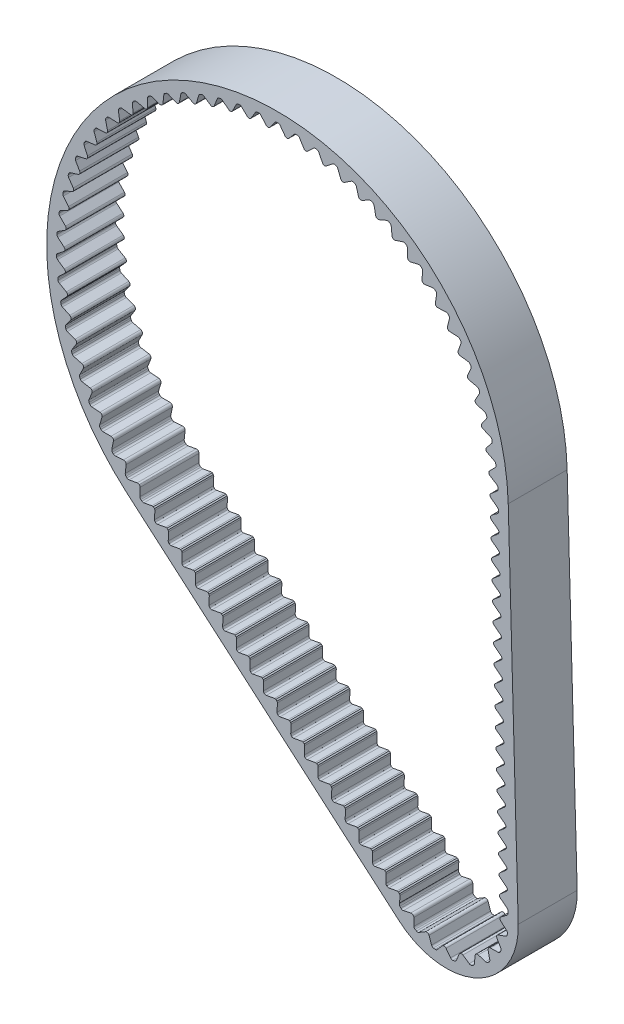
from build123d import *

# Parameters (mm, degrees)
EXTRUSION1_DEPTH = 6


with BuildPart() as part:
    # Esquisse1 → Extrusion1 (new body)
    with BuildSketch(Plane.XY.offset(6)):
        with BuildLine():
            Line((-15.334373102, -17.807498465), (12.39087959, -41.68223696))
            ThreePointArc((12.39087959, -41.68223696), (20.327023581, -42.748267068), (24.509319529, -35.919855668))
            Line((24.509319529, -35.919855668), (23.490894598, 0.654118489))
            ThreePointArc((23.490894598, 0.654118489), (-10.091582426, 21.222864183), (-15.334373102, -17.807498465))
        make_face()
        with BuildLine():
            Line((22.696897189, -34.530290534), (23.358806003, -35.04004493))
            ThreePointArc((23.358806003, -35.04004493), (23.431470071, -35.129563447), (23.45623381, -35.242170679))
            Line((23.45623381, -35.242170679), (23.444067585, -35.24187801))
            ThreePointArc((23.444067585, -35.24187801), (23.452635322, -35.269269708), (23.458007178, -35.29746287))
            ThreePointArc((23.458007178, -35.29746287), (23.467697998, -35.374773495), (23.476437242, -35.452197459))
            ThreePointArc((23.476437242, -35.452197459), (23.45702328, -35.578601158), (23.377639226, -35.678865651))
            Line((23.377639226, -35.678865651), (22.755214675, -36.144674693))
            ThreePointArc((22.755214675, -36.144674693), (22.65519241, -36.335200136), (22.740250266, -36.532860347))
            Line((22.740250266, -36.532860347), (23.324967395, -37.045204239))
            ThreePointArc((23.324967395, -37.045204239), (23.396397014, -37.151282542), (23.406022193, -37.278805688))
            ThreePointArc((23.406022193, -37.278805688), (23.391348414, -37.35532709), (23.375734608, -37.431662231))
            ThreePointArc((23.375734608, -37.431662231), (23.318209943, -37.545880047), (23.211727788, -37.616706225))
            Line((23.211727788, -37.616706225), (22.475823953, -37.867377186))
            ThreePointArc((22.475823953, -37.867377186), (22.321821526, -38.01766907), (22.34163599, -38.231939425))
            Line((22.34163599, -38.231939425), (22.739412056, -38.899894952))
            ThreePointArc((22.739412056, -38.899894952), (22.774565662, -39.02285438), (22.744312933, -39.147110442))
            ThreePointArc((22.744312933, -39.147110442), (22.706710926, -39.215352173), (22.668272458, -39.283126275))
            ThreePointArc((22.668272458, -39.283126275), (22.578268003, -39.373977774), (22.455110964, -39.408432676))
            Line((22.455110964, -39.408432676), (21.677763239, -39.419428136))
            ThreePointArc((21.677763239, -39.419428136), (21.484855482, -39.514774845), (21.437486976, -39.724681068))
            Line((21.437486976, -39.724681068), (21.609384886, -40.482864089))
            ThreePointArc((21.609384886, -40.482864089), (21.604821399, -40.610668516), (21.537652108, -40.719494446))
            ThreePointArc((21.537652108, -40.719494446), (21.48080262, -40.77277653), (21.423302116, -40.825355391))
            ThreePointArc((21.423302116, -40.825355391), (21.309628136, -40.883947396), (21.18185168, -40.878658337))
            Line((21.18185168, -40.878658337), (20.439152277, -40.648901983))
            ThreePointArc((20.439152277, -40.648901983), (20.226222344, -40.679970317), (20.116307628, -40.864965324))
            Line((20.116307628, -40.864965324), (20.045500817, -41.639159603))
            ThreePointArc((20.045500817, -41.639159603), (20.001666943, -41.75929864), (19.90415609, -41.842041798))
            ThreePointArc((19.90415609, -41.842041798), (19.833623944, -41.875148613), (19.762689953, -41.907385449))
            ThreePointArc((19.762689953, -41.907385449), (19.636473648, -41.927982565), (19.516585427, -41.883467274))
            Line((19.516585427, -41.883467274), (18.881234938, -41.43544926))
            ThreePointArc((18.881234938, -41.43544926), (18.669125894, -41.399198033), (18.507424186, -41.541173225))
            Line((18.507424186, -41.541173225), (18.200843718, -42.255595231))
            ThreePointArc((18.200843718, -42.255595231), (18.122030223, -42.356308834), (18.003722848, -42.404869742))
            ThreePointArc((18.003722848, -42.404869742), (17.926412223, -42.414560563), (17.848988259, -42.423299807))
            ThreePointArc((17.848988259, -42.423299807), (17.722584561, -42.403885845), (17.622320067, -42.32450179))
            Line((17.622320067, -42.32450179), (17.156511025, -41.702077239))
            ThreePointArc((17.156511025, -41.702077239), (16.965985582, -41.602054975), (16.768325372, -41.687112831))
            Line((16.768325372, -41.687112831), (16.255981479, -42.27182996))
            ThreePointArc((16.255981479, -42.27182996), (16.149903176, -42.343259578), (16.02238003, -42.352884758))
            ThreePointArc((16.02238003, -42.352884758), (15.945858629, -42.338210979), (15.869523488, -42.322597173))
            ThreePointArc((15.869523488, -42.322597173), (15.755305671, -42.265072507), (15.684479493, -42.158590352))
            Line((15.684479493, -42.158590352), (15.433808532, -41.422686517))
            ThreePointArc((15.433808532, -41.422686517), (15.283516648, -41.268684091), (15.069246294, -41.288498555))
            Line((15.069246294, -41.288498555), (14.401290766, -41.68627462))
            ThreePointArc((14.401290766, -41.68627462), (14.278331339, -41.721428227), (14.154075276, -41.691175497))
            ThreePointArc((14.154075276, -41.691175497), (14.085833545, -41.65357349), (14.018059444, -41.615135023))
            ThreePointArc((14.018059444, -41.615135023), (13.927207944, -41.525130568), (13.892753042, -41.401973528))
            Line((13.892753042, -41.401973528), (13.881757582, -40.624625803))
            ThreePointArc((13.881757582, -40.624625803), (13.786410873, -40.431718046), (13.57650465, -40.38434954))
            Line((13.57650465, -40.38434954), (12.818321629, -40.55624745))
            ThreePointArc((12.818321629, -40.55624745), (12.690517202, -40.551683964), (12.581691272, -40.484514673))
            ThreePointArc((12.581691272, -40.484514673), (12.557507119, -40.458884888), (12.533465906, -40.433120975))
            Line((12.533465906, -40.433120975), (12.529931343, -40.437684395))
            ThreePointArc((12.529931343, -40.437684395), (12.489724532, -40.397890711), (12.459493698, -40.350076261))
            ThreePointArc((12.459493698, -40.350076261), (12.414775023, -40.243776449), (12.422527382, -40.128714244))
            Line((12.422527382, -40.128714244), (12.438908993, -40.075759831))
            Line((12.438908993, -40.075759831), (12.457051161, -39.399390639))
            ThreePointArc((12.457051161, -39.399390639), (12.448764535, -39.32837889), (12.420717879, -39.262616273))
            Line((12.420717879, -39.262616273), (12.304238174, -39.162313401))
            ThreePointArc((12.304238174, -39.162313401), (12.234237521, -39.144160107), (12.161969594, -39.146802114))
            Line((12.161969594, -39.146802114), (11.340272659, -39.297755652))
            ThreePointArc((11.340272659, -39.297755652), (11.225124598, -39.291877256), (11.124860429, -39.234949864))
            Line((11.124860429, -39.234949864), (11.128174206, -39.230671498))
            ThreePointArc((11.128174206, -39.230671498), (11.06804321, -39.1444171), (11.04869629, -39.041066945))
            Line((11.04869629, -39.041066945), (11.071097344, -38.205919643))
            ThreePointArc((11.071097344, -38.205919643), (11.062810718, -38.134907894), (11.034764062, -38.069145277))
            Line((11.034764062, -38.069145277), (10.918284358, -37.968842405))
            ThreePointArc((10.918284358, -37.968842405), (10.848283704, -37.950689111), (10.776015777, -37.953331118))
            Line((10.776015777, -37.953331118), (9.954318843, -38.104284656))
            ThreePointArc((9.954318843, -38.104284656), (9.839170781, -38.09840626), (9.738906612, -38.041478869))
            Line((9.738906612, -38.041478869), (9.742220389, -38.037200502))
            ThreePointArc((9.742220389, -38.037200502), (9.682089393, -37.950946104), (9.662742474, -37.847595949))
            Line((9.662742474, -37.847595949), (9.685143527, -37.012448647))
            ThreePointArc((9.685143527, -37.012448647), (9.676856902, -36.941436898), (9.648810245, -36.875674281))
            Line((9.648810245, -36.875674281), (9.532330541, -36.775371409))
            ThreePointArc((9.532330541, -36.775371409), (9.462329888, -36.757218115), (9.39006196, -36.759860122))
            Line((9.39006196, -36.759860122), (8.568365026, -36.91081366))
            ThreePointArc((8.568365026, -36.91081366), (8.453216965, -36.904935265), (8.352952796, -36.848007873))
            Line((8.352952796, -36.848007873), (8.356266572, -36.843729506))
            ThreePointArc((8.356266572, -36.843729506), (8.296135577, -36.757475108), (8.276788657, -36.654124953))
            Line((8.276788657, -36.654124953), (8.299189711, -35.818977652))
            ThreePointArc((8.299189711, -35.818977652), (8.290903085, -35.747965902), (8.262856429, -35.682203286))
            Line((8.262856429, -35.682203286), (8.146376724, -35.581900413))
            ThreePointArc((8.146376724, -35.581900413), (8.076376071, -35.563747119), (8.004108144, -35.566389126))
            Line((8.004108144, -35.566389126), (7.182411209, -35.717342665))
            ThreePointArc((7.182411209, -35.717342665), (7.067263148, -35.711464269), (6.966998979, -35.654536877))
            Line((6.966998979, -35.654536877), (6.970312756, -35.65025851))
            ThreePointArc((6.970312756, -35.65025851), (6.91018176, -35.564004112), (6.89083484, -35.460653957))
            Line((6.89083484, -35.460653957), (6.913235894, -34.625506656))
            ThreePointArc((6.913235894, -34.625506656), (6.904949268, -34.554494907), (6.876902612, -34.48873229))
            Line((6.876902612, -34.48873229), (6.760422908, -34.388429417))
            ThreePointArc((6.760422908, -34.388429417), (6.690422254, -34.370276123), (6.618154327, -34.37291813))
            Line((6.618154327, -34.37291813), (5.796457393, -34.523871669))
            ThreePointArc((5.796457393, -34.523871669), (5.681309331, -34.517993273), (5.581045162, -34.461065881))
            Line((5.581045162, -34.461065881), (5.584358939, -34.456787515))
            ThreePointArc((5.584358939, -34.456787515), (5.524227943, -34.370533116), (5.504881024, -34.267182961))
            Line((5.504881024, -34.267182961), (5.527282077, -33.43203566))
            ThreePointArc((5.527282077, -33.43203566), (5.518995452, -33.361023911), (5.490948795, -33.295261294))
            Line((5.490948795, -33.295261294), (5.374469091, -33.194958422))
            ThreePointArc((5.374469091, -33.194958422), (5.304468438, -33.176805128), (5.23220051, -33.179447134))
            Line((5.23220051, -33.179447134), (4.410503576, -33.330400673))
            ThreePointArc((4.410503576, -33.330400673), (4.295355515, -33.324522277), (4.195091346, -33.267594885))
            Line((4.195091346, -33.267594885), (4.198405122, -33.263316519))
            ThreePointArc((4.198405122, -33.263316519), (4.138274127, -33.177062121), (4.118927207, -33.073711966))
            Line((4.118927207, -33.073711966), (4.141328261, -32.238564664))
            ThreePointArc((4.141328261, -32.238564664), (4.133041635, -32.167552915), (4.104994979, -32.101790298))
            Line((4.104994979, -32.101790298), (3.988515274, -32.001487426))
            ThreePointArc((3.988515274, -32.001487426), (3.918514621, -31.983334132), (3.846246693, -31.985976139))
            Line((3.846246693, -31.985976139), (3.024549759, -32.136929677))
            ThreePointArc((3.024549759, -32.136929677), (2.909401698, -32.131051281), (2.809137529, -32.074123889))
            Line((2.809137529, -32.074123889), (2.812451306, -32.069845523))
            ThreePointArc((2.812451306, -32.069845523), (2.75232031, -31.983591125), (2.73297339, -31.88024097))
            Line((2.73297339, -31.88024097), (2.755374444, -31.045093668))
            ThreePointArc((2.755374444, -31.045093668), (2.747087818, -30.974081919), (2.719041162, -30.908319302))
            Line((2.719041162, -30.908319302), (2.602561458, -30.80801643))
            ThreePointArc((2.602561458, -30.80801643), (2.532560804, -30.789863136), (2.460292877, -30.792505143))
            Line((2.460292877, -30.792505143), (1.638595942, -30.943458681))
            ThreePointArc((1.638595942, -30.943458681), (1.523447881, -30.937580285), (1.423183712, -30.880652893))
            Line((1.423183712, -30.880652893), (1.426497489, -30.876374527))
            ThreePointArc((1.426497489, -30.876374527), (1.366366493, -30.790120129), (1.347019573, -30.686769974))
            Line((1.347019573, -30.686769974), (1.369420627, -29.851622672))
            ThreePointArc((1.369420627, -29.851622672), (1.361134001, -29.780610923), (1.333087345, -29.714848306))
            Line((1.333087345, -29.714848306), (1.216607641, -29.614545434))
            ThreePointArc((1.216607641, -29.614545434), (1.146606988, -29.59639214), (1.07433906, -29.599034147))
            Line((1.07433906, -29.599034147), (0.252642126, -29.749987685))
            ThreePointArc((0.252642126, -29.749987685), (0.137494065, -29.744109289), (0.037229896, -29.687181898))
            Line((0.037229896, -29.687181898), (0.040543672, -29.682903531))
            ThreePointArc((0.040543672, -29.682903531), (-0.019587323, -29.596649133), (-0.038934243, -29.493298978))
            Line((-0.038934243, -29.493298978), (-0.01653319, -28.658151676))
            ThreePointArc((-0.01653319, -28.658151676), (-0.024819815, -28.587139927), (-0.052866472, -28.52137731))
            Line((-0.052866472, -28.52137731), (-0.169346176, -28.421074438))
            ThreePointArc((-0.169346176, -28.421074438), (-0.239346829, -28.402921144), (-0.311614757, -28.405563151))
            Line((-0.311614757, -28.405563151), (-1.133311691, -28.556516689))
            ThreePointArc((-1.133311691, -28.556516689), (-1.248459752, -28.550638294), (-1.348723921, -28.493710902))
            Line((-1.348723921, -28.493710902), (-1.345410144, -28.489432535))
            ThreePointArc((-1.345410144, -28.489432535), (-1.40554114, -28.403178137), (-1.42488806, -28.299827982))
            Line((-1.42488806, -28.299827982), (-1.402487006, -27.464680681))
            ThreePointArc((-1.402487006, -27.464680681), (-1.410773632, -27.393668931), (-1.438820288, -27.327906315))
            Line((-1.438820288, -27.327906315), (-1.555299993, -27.227603442))
            ThreePointArc((-1.555299993, -27.227603442), (-1.625300646, -27.209450148), (-1.697568573, -27.212092155))
            Line((-1.697568573, -27.212092155), (-2.519265508, -27.363045694))
            ThreePointArc((-2.519265508, -27.363045694), (-2.634413569, -27.357167298), (-2.734677738, -27.300239906))
            Line((-2.734677738, -27.300239906), (-2.731363961, -27.295961539))
            ThreePointArc((-2.731363961, -27.295961539), (-2.791494957, -27.209707141), (-2.810841877, -27.106356986))
            Line((-2.810841877, -27.106356986), (-2.788440823, -26.271209685))
            ThreePointArc((-2.788440823, -26.271209685), (-2.796727449, -26.200197935), (-2.824774105, -26.134435319))
            Line((-2.824774105, -26.134435319), (-2.941253809, -26.034132446))
            ThreePointArc((-2.941253809, -26.034132446), (-3.011254463, -26.015979152), (-3.08352239, -26.018621159))
            Line((-3.08352239, -26.018621159), (-3.905219324, -26.169574698))
            ThreePointArc((-3.905219324, -26.169574698), (-4.020367386, -26.163696302), (-4.120631555, -26.10676891))
            Line((-4.120631555, -26.10676891), (-4.117317778, -26.102490544))
            ThreePointArc((-4.117317778, -26.102490544), (-4.177448774, -26.016236145), (-4.196795693, -25.91288599))
            Line((-4.196795693, -25.91288599), (-4.17439464, -25.077738689))
            ThreePointArc((-4.17439464, -25.077738689), (-4.182681265, -25.00672694), (-4.210727922, -24.940964323))
            Line((-4.210727922, -24.940964323), (-4.327207626, -24.840661451))
            ThreePointArc((-4.327207626, -24.840661451), (-4.397208279, -24.822508157), (-4.469476207, -24.825150163))
            Line((-4.469476207, -24.825150163), (-5.291173141, -24.976103702))
            ThreePointArc((-5.291173141, -24.976103702), (-5.406321202, -24.970225306), (-5.506585371, -24.913297914))
            Line((-5.506585371, -24.913297914), (-5.503271595, -24.909019548))
            ThreePointArc((-5.503271595, -24.909019548), (-5.56340259, -24.82276515), (-5.58274951, -24.719414995))
            Line((-5.58274951, -24.719414995), (-5.560348456, -23.884267693))
            ThreePointArc((-5.560348456, -23.884267693), (-5.568635082, -23.813255944), (-5.596681738, -23.747493327))
            Line((-5.596681738, -23.747493327), (-5.713161443, -23.647190455))
            ThreePointArc((-5.713161443, -23.647190455), (-5.783162096, -23.629037161), (-5.855430023, -23.631679168))
            Line((-5.855430023, -23.631679168), (-6.677126958, -23.782632706))
            ThreePointArc((-6.677126958, -23.782632706), (-6.792275019, -23.77675431), (-6.892539188, -23.719826918))
            Line((-6.892539188, -23.719826918), (-6.889225411, -23.715548552))
            ThreePointArc((-6.889225411, -23.715548552), (-6.949356407, -23.629294154), (-6.968703327, -23.525943999))
            Line((-6.968703327, -23.525943999), (-6.946302273, -22.690796697))
            ThreePointArc((-6.946302273, -22.690796697), (-6.954588899, -22.619784948), (-6.982635555, -22.554022331))
            Line((-6.982635555, -22.554022331), (-7.099115259, -22.453719459))
            ThreePointArc((-7.099115259, -22.453719459), (-7.169115913, -22.435566165), (-7.24138384, -22.438208172))
            Line((-7.24138384, -22.438208172), (-8.063080774, -22.58916171))
            ThreePointArc((-8.063080774, -22.58916171), (-8.178228836, -22.583283314), (-8.278493005, -22.526355922))
            Line((-8.278493005, -22.526355922), (-8.275179228, -22.522077556))
            ThreePointArc((-8.275179228, -22.522077556), (-8.335310224, -22.435823158), (-8.354657144, -22.332473003))
            Line((-8.354657144, -22.332473003), (-8.33225609, -21.497325701))
            ThreePointArc((-8.33225609, -21.497325701), (-8.340542715, -21.426313952), (-8.368589372, -21.360551335))
            Line((-8.368589372, -21.360551335), (-8.485069076, -21.260248463))
            ThreePointArc((-8.485069076, -21.260248463), (-8.555069729, -21.242095169), (-8.627337657, -21.244737176))
            Line((-8.627337657, -21.244737176), (-9.449034591, -21.395690714))
            ThreePointArc((-9.449034591, -21.395690714), (-9.564182652, -21.389812318), (-9.664446821, -21.332884926))
            Line((-9.664446821, -21.332884926), (-9.661133045, -21.32860656))
            ThreePointArc((-9.661133045, -21.32860656), (-9.72126404, -21.242352162), (-9.74061096, -21.139002007))
            Line((-9.74061096, -21.139002007), (-9.718209907, -20.303854705))
            ThreePointArc((-9.718209907, -20.303854705), (-9.726496532, -20.232842956), (-9.754543188, -20.167080339))
            Line((-9.754543188, -20.167080339), (-9.871022893, -20.066777467))
            ThreePointArc((-9.871022893, -20.066777467), (-9.941023546, -20.048624173), (-10.013291474, -20.05126618))
            Line((-10.013291474, -20.05126618), (-10.834988408, -20.202219718))
            ThreePointArc((-10.834988408, -20.202219718), (-10.950136469, -20.196341323), (-11.050400638, -20.139413931))
            Line((-11.050400638, -20.139413931), (-11.047086861, -20.135135564))
            ThreePointArc((-11.047086861, -20.135135564), (-11.107217857, -20.048881166), (-11.126564777, -19.945531011))
            Line((-11.126564777, -19.945531011), (-11.104163723, -19.11038371))
            ThreePointArc((-11.104163723, -19.11038371), (-11.112450349, -19.03937196), (-11.140497005, -18.973609344))
            Line((-11.140497005, -18.973609344), (-11.25697671, -18.873306471))
            ThreePointArc((-11.25697671, -18.873306471), (-11.326977363, -18.855153177), (-11.39924529, -18.857795184))
            Line((-11.39924529, -18.857795184), (-12.220942225, -19.008748723))
            ThreePointArc((-12.220942225, -19.008748723), (-12.336090286, -19.002870327), (-12.436354455, -18.945942935))
            Line((-12.436354455, -18.945942935), (-12.433040678, -18.941664568))
            ThreePointArc((-12.433040678, -18.941664568), (-12.493171674, -18.85541017), (-12.512518594, -18.752060015))
            Line((-12.512518594, -18.752060015), (-12.49011754, -17.916912714))
            ThreePointArc((-12.49011754, -17.916912714), (-12.498404166, -17.845900964), (-12.526450822, -17.780138348))
            Line((-12.526450822, -17.780138348), (-12.642930526, -17.679835475))
            ThreePointArc((-12.642930526, -17.679835475), (-12.71293118, -17.661682181), (-12.785199107, -17.664324188))
            Line((-12.785199107, -17.664324188), (-13.606896041, -17.815277727))
            ThreePointArc((-13.606896041, -17.815277727), (-13.711359306, -17.812259718), (-13.80546151, -17.766801414))
            ThreePointArc((-13.80546151, -17.766801414), (-13.861098453, -17.7234294), (-13.916599136, -17.679883158))
            ThreePointArc((-13.916599136, -17.679883158), (-13.988310863, -17.589599938), (-14.011880372, -17.476736703))
            Line((-14.011880372, -17.476736703), (-13.989479318, -16.641589402))
            ThreePointArc((-13.989479318, -16.641589402), (-14.009390978, -16.536902879), (-14.071091487, -16.450019111))
            Line((-14.071091487, -16.450019111), (-14.081548407, -16.44101446))
            ThreePointArc((-14.081548407, -16.44101446), (-14.177341376, -16.392708393), (-14.284560886, -16.389000876))
            Line((-14.284560886, -16.389000876), (-15.10625782, -16.539954415))
            ThreePointArc((-15.10625782, -16.539954415), (-15.221405881, -16.534076019), (-15.32167005, -16.477148627))
            ThreePointArc((-15.32167005, -16.477148627), (-15.373256052, -16.429029136), (-15.424690931, -16.380748142))
            ThreePointArc((-15.424690931, -16.380748142), (-15.488142796, -16.284480327), (-15.501645209, -16.16997567))
            Line((-15.501645209, -16.16997567), (-15.405521409, -15.340076256))
            ThreePointArc((-15.405521409, -15.340076256), (-15.475139808, -15.136501671), (-15.677124469, -15.062396815))
            Line((-15.677124469, -15.062396815), (-16.508947246, -15.140137984))
            ThreePointArc((-16.508947246, -15.140137984), (-16.62312518, -15.124105794), (-16.717965748, -15.058539811))
            ThreePointArc((-16.717965748, -15.058539811), (-16.76509708, -15.006049444), (-16.812063605, -14.953411562))
            ThreePointArc((-16.812063605, -14.953411562), (-16.866759012, -14.851912577), (-16.870088654, -14.736662653))
            Line((-16.870088654, -14.736662653), (-16.700994407, -13.918506215))
            ThreePointArc((-16.700994407, -13.918506215), (-16.752348434, -13.709575372), (-16.946993298, -13.617909076))
            Line((-16.946993298, -13.617909076), (-17.782431777, -13.621829446))
            ThreePointArc((-17.782431777, -13.621829446), (-17.894745985, -13.595768935), (-17.983420697, -13.522077504))
            ThreePointArc((-17.983420697, -13.522077504), (-18.025728491, -13.465627069), (-18.067859087, -13.409044262))
            ThreePointArc((-18.067859087, -13.409044262), (-18.11336997, -13.303108475), (-18.106500783, -13.18801527))
            Line((-18.106500783, -13.18801527), (-17.865759479, -12.388004991))
            ThreePointArc((-17.865759479, -12.388004991), (-17.898447219, -12.175353058), (-18.084228926, -12.066842734))
            Line((-18.084228926, -12.066842734), (-18.916744669, -11.996911623))
            ThreePointArc((-18.916744669, -11.996911623), (-19.026316141, -11.96102675), (-19.108130997, -11.879786607))
            ThreePointArc((-19.108130997, -11.879786607), (-19.145284137, -11.819817905), (-19.182249074, -11.75973301))
            ThreePointArc((-19.182249074, -11.75973301), (-19.218219249, -11.650189512), (-19.201204992, -11.536153787))
            Line((-19.201204992, -11.536153787), (-18.89070076, -10.760550832))
            ThreePointArc((-18.89070076, -10.760550832), (-18.904466387, -10.545842098), (-19.079930944, -10.421336988))
            Line((-19.079930944, -10.421336988), (-19.903008385, -10.278101701))
            ThreePointArc((-19.903008385, -10.278101701), (-20.008979576, -10.232673313), (-20.083294263, -10.144520272))
            ThreePointArc((-20.083294263, -10.144520272), (-20.115001977, -10.08150264), (-20.146511954, -10.018385903))
            ThreePointArc((-20.146511954, -10.018385903), (-20.172659906, -9.90609202), (-20.145633739, -9.794006259))
            Line((-20.145633739, -9.794006259), (-19.767796695, -9.048880773))
            ThreePointArc((-19.767796695, -9.048880773), (-19.762532474, -8.833795625), (-19.926306632, -8.694270149))
            Line((-19.926306632, -8.694270149), (-20.733504076, -8.478851697))
            ThreePointArc((-20.733504076, -8.478851697), (-20.835045616, -8.424235334), (-20.901278522, -8.329859311))
            ThreePointArc((-20.901278522, -8.329859311), (-20.927292653, -8.264285947), (-20.953101062, -8.198631343))
            ThreePointArc((-20.953101062, -8.198631343), (-20.969222147, -8.084465927), (-20.932395588, -7.975207353))
            Line((-20.932395588, -7.975207353), (-20.490182819, -7.266390953))
            ThreePointArc((-20.490182819, -7.266390953), (-20.46592995, -7.052612723), (-20.616731954, -6.899158859))
            Line((-20.616731954, -6.899158859), (-21.401731985, -6.613243183))
            ThreePointArc((-21.401731985, -6.613243183), (-21.498049176, -6.549866292), (-21.555681937, -6.450005908))
            ThreePointArc((-21.555681937, -6.450005908), (-21.57579889, -6.382390013), (-21.595703745, -6.314711376))
            ThreePointArc((-21.595703745, -6.314711376), (-21.601671794, -6.199567927), (-21.555333059, -6.093991636))
            Line((-21.555333059, -6.093991636), (-21.05220548, -5.427031771))
            ThreePointArc((-21.05220548, -5.427031771), (-21.009153775, -5.216233565), (-21.145803395, -5.050052296))
            Line((-21.145803395, -5.050052296), (-21.902462324, -4.695877075))
            ThreePointArc((-21.902462324, -4.695877075), (-21.992801352, -4.624235665), (-22.041382916, -4.519672463))
            ThreePointArc((-22.041382916, -4.519672463), (-22.055445247, -4.450543222), (-22.069290766, -4.381370231))
            ThreePointArc((-22.069290766, -4.381370231), (-22.065059071, -4.266149902), (-22.009570824, -4.165082172))
            Line((-22.009570824, -4.165082172), (-21.44946609, -3.545198708))
            ThreePointArc((-21.44946609, -3.545198708), (-21.387952486, -3.339030307), (-21.509380254, -3.161422227))
            Line((-21.509380254, -3.161422227), (-22.231776199, -2.741759361))
            ThreePointArc((-22.231776199, -2.741759361), (-22.315430039, -2.662414124), (-22.354580187, -2.553966453))
            ThreePointArc((-22.354580187, -2.553966453), (-22.362477841, -2.483864897), (-22.370155663, -2.413738924))
            ThreePointArc((-22.370155663, -2.413738924), (-22.355757343, -2.29934347), (-22.291553855, -2.203575293))
            Line((-22.291553855, -2.203575293), (-21.678855545, -1.635619658))
            ThreePointArc((-21.678855545, -1.635619658), (-21.59936147, -1.43569461), (-21.704617049, -1.248049743))
            Line((-21.704617049, -1.248049743), (-22.387096282, -0.766183663))
            ThreePointArc((-22.387096282, -0.766183663), (-22.46341023, -0.679755583), (-22.49282256, -0.568272192))
            ThreePointArc((-22.49282256, -0.568272192), (-22.494493725, -0.497746961), (-22.495943763, -0.427216837))
            ThreePointArc((-22.495943763, -0.427216837), (-22.471491504, -0.314541557), (-22.399075254, -0.224822449))
            Line((-22.399075254, -0.224822449), (-21.738578563, 0.286760333))
            ThreePointArc((-21.738578563, 0.286760333), (-21.641726165, 0.478877345), (-21.729985788, 0.675090423))
            Line((-21.729985788, 0.675090423), (-22.367206984, 1.215388461))
            ThreePointArc((-22.367206984, 1.215388461), (-22.435583778, 1.308222967), (-22.455028099, 1.421869568))
            ThreePointArc((-22.455028099, 1.421869568), (-22.450459698, 1.49226652), (-22.445670601, 1.562648802))
            ThreePointArc((-22.445670601, 1.562648802), (-22.411355775, 1.672722069), (-22.331293519, 1.755689935))
            Line((-22.331293519, 1.755689935), (-21.628167729, 2.206896036))
            ThreePointArc((-21.628167729, 2.206896036), (-21.514715011, 2.389701435), (-21.585287925, 2.592947091))
            Line((-21.585287925, 2.592947091), (-22.172263964, 3.187448523))
            ThreePointArc((-22.172263964, 3.187448523), (-22.232168464, 3.285962899), (-22.241492598, 3.400883272))
            ThreePointArc((-22.241492598, 3.400883272), (-22.230720383, 3.470600992), (-22.219729634, 3.540284594))
            ThreePointArc((-22.219729634, 3.540284594), (-22.175820801, 3.646894378), (-22.088739134, 3.722461664))
            Line((-22.088739134, 3.722461664), (-21.348487158, 4.109759786))
            ThreePointArc((-21.348487158, 4.109759786), (-21.21932204, 4.281822871), (-21.271655918, 4.490510432))
            Line((-21.271655918, 4.490510432), (-21.803792916, 5.134562478))
            ThreePointArc((-21.803792916, 5.134562478), (-21.854756289, 5.237985716), (-21.85388726, 5.353280453))
            ThreePointArc((-21.85388726, 5.353280453), (-21.83699554, 5.421773305), (-21.819889155, 5.49021286))
            ThreePointArc((-21.819889155, 5.49021286), (-21.766729962, 5.592524793), (-21.673310416, 5.660100085))
            Line((-21.673310416, 5.660100085), (-20.901725729, 5.980459092))
            ThreePointArc((-20.901725729, 5.980459092), (-20.757859104, 6.140433237), (-20.791544362, 6.352929441))
            Line((-20.791544362, 6.352929441), (-21.264677626, 7.04149152))
            ThreePointArc((-21.264677626, 7.04149152), (-21.306301013, 7.149014193), (-21.295245625, 7.263780956))
            ThreePointArc((-21.295245625, 7.263780956), (-21.2723666, 7.330512892), (-21.24927846, 7.397172766))
            ThreePointArc((-21.24927846, 7.397172766), (-21.187284948, 7.494386119), (-21.088258659, 7.553440548))
            Line((-21.088258659, 7.553440548), (-20.291379957, 7.804353198))
            ThreePointArc((-20.291379957, 7.804353198), (-20.133937776, 7.950986389), (-20.148710781, 8.165628163))
            Line((-20.148710781, 8.165628163), (-20.559137402, 8.893311343))
            ThreePointArc((-20.559137402, 8.893311343), (-20.591095044, 9.00409194), (-20.569939819, 9.117432524))
            ThreePointArc((-20.569939819, 9.117432524), (-20.541252548, 9.181881275), (-20.51236335, 9.246239766))
            ThreePointArc((-20.51236335, 9.246239766), (-20.442020704, 9.337593713), (-20.338162685, 9.387665097))
            Line((-20.338162685, 9.387665097), (-19.522226625, 9.567167658))
            ThreePointArc((-19.522226625, 9.567167658), (-19.352441087, 9.699312291), (-19.348186219, 9.914419773))
            Line((-19.348186219, 9.914419773), (-19.692694053, 10.675528948))
            ThreePointArc((-19.692694053, 10.675528948), (-19.714735838, 10.78870046), (-19.683646345, 10.899727821))
            ThreePointArc((-19.683646345, 10.899727821), (-19.649375345, 10.961388989), (-19.614911185, 11.022942403))
            ThreePointArc((-19.614911185, 11.022942403), (-19.53676993, 11.107721975), (-19.428893012, 11.148418438))
            Line((-19.428893012, 11.148418438), (-18.600285401, 11.25510606))
            ThreePointArc((-18.600285401, 11.25510606), (-18.419485307, 11.371727923), (-18.396235867, 11.585617607))
            Line((-18.396235867, 11.585617607), (-18.672128672, 12.374196064))
            ThreePointArc((-18.672128672, 12.374196064), (-18.684082094, 12.488872771), (-18.643301649, 12.59671797))
            ThreePointArc((-18.643301649, 12.59671797), (-18.603715137, 12.655108972), (-18.563945745, 12.71337557))
            ThreePointArc((-18.563945745, 12.71337557), (-18.478617444, 12.790917253), (-18.367565909, 12.82192029))
            Line((-18.367565909, 12.82192029), (-17.532771724, 12.854957997))
            ThreePointArc((-17.532771724, 12.854957997), (-17.34237208, 12.955144367), (-17.300310027, 13.166142274))
            Line((-17.300310027, 13.166142274), (-17.505428568, 13.976018318))
            ThreePointArc((-17.505428568, 13.976018318), (-17.507200075, 14.09130272), (-17.457047841, 14.195121721))
            ThreePointArc((-17.457047841, 14.195121721), (-17.412455635, 14.249785569), (-17.367692259, 14.304309336))
            ThreePointArc((-17.367692259, 14.304309336), (-17.275844721, 14.37400626), (-17.1624877, 14.395073231))
            Line((-17.1624877, 14.395073231), (-16.328040336, 14.354202458))
            ThreePointArc((-16.328040336, 14.354202458), (-16.129531278, 14.43716924), (-16.068985805, 14.643624026))
            Line((-16.068985805, 14.643624026), (-16.20172475, 15.468459279))
            ThreePointArc((-16.20172475, 15.468459279), (-16.193300477, 15.583449119), (-16.134168964, 15.682429398))
            ThreePointArc((-16.134168964, 15.682429398), (-16.084920059, 15.732938273), (-16.035513034, 15.783292487))
            ThreePointArc((-16.035513034, 15.783292487), (-15.93786509, 15.84459918), (-15.823089754, 15.855565206))
            Line((-15.823089754, 15.855565206), (-14.995519894, 15.741105822))
            ThreePointArc((-14.995519894, 15.741105822), (-14.790455025, 15.80620369), (-14.711899981, 16.006499566))
            Line((-14.711899981, 16.006499566), (-14.77122047, 16.839838574))
            ThreePointArc((-14.77122047, 16.839838574), (-14.752666348, 16.9536339), (-14.68501834, 17.047000802))
            ThreePointArc((-14.68501834, 17.047000802), (-14.631498175, 17.092959403), (-14.577834178, 17.138749975))
            ThreePointArc((-14.577834178, 17.138749975), (-14.475150055, 17.191186628), (-14.359854677, 17.191965886))
            Line((-14.359854677, 17.191965886), (-13.545639178, 17.004813691))
            ThreePointArc((-13.545639178, 17.004813691), (-13.335623408, 17.051533165), (-13.239673593, 17.244102545))
            Line((-13.239673593, 17.244102545), (-13.225111361, 18.0794233))
            ThreePointArc((-13.225111361, 18.0794233), (-13.196572603, 18.191133509), (-13.120937536, 18.278156312))
            ThreePointArc((-13.120937536, 18.278156312), (-13.063564979, 18.319204951), (-13.006064003, 18.360073506))
            ThreePointArc((-13.006064003, 18.360073506), (-12.899147345, 18.403229732), (-12.784234267, 18.393816123))
            Line((-12.784234267, 18.393816123), (-11.989745469, 18.135435837))
            ThreePointArc((-11.989745469, 18.135435837), (-11.776422456, 18.163411273), (-11.663828808, 18.34674704))
            Line((-11.663828808, 18.34674704), (-11.575497825, 19.177512025))
            ThreePointArc((-11.575497825, 19.177512025), (-11.537197784, 19.286262834), (-11.454167607, 19.366260466))
            ThreePointArc((-11.454167607, 19.366260466), (-11.393391676, 19.402077882), (-11.332503744, 19.437704569))
            ThreePointArc((-11.332503744, 19.437704569), (-11.222191318, 19.471242611), (-11.108559891, 19.451709809))
            Line((-11.108559891, 19.451709809), (-10.340015746, 19.124123609))
            ThreePointArc((-10.340015746, 19.124123609), (-10.125055031, 19.133136061), (-9.996698748, 19.305803365))
            Line((-9.996698748, 19.305803365), (-9.835290324, 20.125510717))
            ThreePointArc((-9.835290324, 20.125510717), (-9.78752875, 20.230451003), (-9.697753285, 20.302797374))
            ThreePointArc((-9.697753285, 20.302797374), (-9.634049634, 20.333103247), (-9.570251277, 20.363209238))
            ThreePointArc((-9.570251277, 20.363209238), (-9.457406428, 20.386866617), (-9.345945972, 20.357367493))
            Line((-9.345945972, 20.357367493), (-8.609361379, 19.963139183))
            ThreePointArc((-8.609361379, 19.963139183), (-8.394445323, 19.953118119), (-8.251330967, 20.113765602))
            Line((-8.251330967, 20.113765602), (-8.018108341, 20.916))
            ThreePointArc((-8.018108341, 20.916), (-7.961259033, 21.016308463), (-7.865440895, 21.080437365))
            ThreePointArc((-7.865440895, 21.080437365), (-7.799308092, 21.10499451), (-7.733098619, 21.129344186))
            ThreePointArc((-7.733098619, 21.129344186), (-7.61860451, 21.14293575), (-7.510187354, 21.103701175))
            Line((-7.510187354, 21.103701175), (-6.811327087, 20.645916127))
            ThreePointArc((-6.811327087, 20.645916127), (-6.598137699, 20.616939973), (-6.441385333, 20.764310352))
            Line((-6.441385333, 20.764310352), (-6.138173788, 21.542793224))
            ThreePointArc((-6.138173788, 21.542793224), (-6.072681669, 21.637684815), (-5.971570766, 21.693094352))
            ThreePointArc((-5.971570766, 21.693094352), (-5.903526389, 21.711710577), (-5.835423979, 21.730113368))
            ThreePointArc((-5.835423979, 21.730113368), (-5.720176682, 21.733532744), (-5.615651338, 21.684869781))
            Line((-5.615651338, 21.684869781), (-4.959984926, 21.167110784))
            ThreePointArc((-4.959984926, 21.167110784), (-4.7501907, 21.119406318), (-4.581027125, 21.252346221))
            Line((-4.581027125, 21.252346221), (-4.210199704, 22.000984883))
            ThreePointArc((-4.210199704, 22.000984883), (-4.136577338, 22.089716945), (-4.030965, 22.135973463))
            ThreePointArc((-4.030965, 22.135973463), (-3.961541589, 22.14850307), (-3.892079234, 22.16081495))
            ThreePointArc((-3.892079234, 22.16081495), (-3.776980716, 22.154035377), (-3.677165236, 22.09632488))
            Line((-3.677165236, 22.09632488), (-3.069824157, 21.5226441))
            ThreePointArc((-3.069824157, 21.5226441), (-2.86506702, 21.456584675), (-2.684816169, 21.574053665))
            Line((-2.684816169, 21.574053665), (-2.249275098, 22.286989005))
            ThreePointArc((-2.249275098, 22.286989005), (-2.168098681, 22.36886709), (-2.058811466, 22.405608569))
            ThreePointArc((-2.058811466, 22.405608569), (-1.988552353, 22.411953497), (-1.918273692, 22.418078108))
            ThreePointArc((-1.918273692, 22.418078108), (-1.804224754, 22.401152645), (-1.70990033, 22.334846277))
            Line((-1.70990033, 22.334846277), (-1.155637852, 21.709733544))
            ThreePointArc((-1.155637852, 21.709733544), (-0.957520305, 21.625836164), (-0.767592886, 21.726914889))
            Line((-0.767592886, 21.726914889), (-0.270746865, 22.39856722))
            ThreePointArc((-0.270746865, 22.39856722), (-0.182651712, 22.472950522), (-0.070544942, 22.499889409))
            ThreePointArc((-0.070544942, 22.499889409), (0, 22.5), (0.070544942, 22.499889409))
            ThreePointArc((0.070544942, 22.499889409), (0.182651712, 22.472950522), (0.270746865, 22.39856722))
            Line((0.270746865, 22.39856722), (0.767592886, 21.726914889))
            ThreePointArc((0.767592886, 21.726914889), (0.957520305, 21.625836164), (1.155637852, 21.709733544))
            Line((1.155637852, 21.709733544), (1.70990033, 22.334846277))
            ThreePointArc((1.70990033, 22.334846277), (1.804224754, 22.401152645), (1.918273692, 22.418078108))
            ThreePointArc((1.918273692, 22.418078108), (1.988552353, 22.411953497), (2.058811466, 22.405608569))
            ThreePointArc((2.058811466, 22.405608569), (2.168098681, 22.36886709), (2.249275098, 22.286989005))
            Line((2.249275098, 22.286989005), (2.684816169, 21.574053665))
            ThreePointArc((2.684816169, 21.574053665), (2.86506702, 21.456584675), (3.069824157, 21.5226441))
            Line((3.069824157, 21.5226441), (3.677165236, 22.09632488))
            ThreePointArc((3.677165236, 22.09632488), (3.776980716, 22.154035377), (3.892079234, 22.16081495))
            ThreePointArc((3.892079234, 22.16081495), (3.961541589, 22.14850307), (4.030965, 22.135973463))
            ThreePointArc((4.030965, 22.135973463), (4.136577338, 22.089716945), (4.210199704, 22.000984883))
            Line((4.210199704, 22.000984883), (4.581027125, 21.252346221))
            ThreePointArc((4.581027125, 21.252346221), (4.7501907, 21.119406318), (4.959984926, 21.167110784))
            Line((4.959984926, 21.167110784), (5.615651338, 21.684869781))
            ThreePointArc((5.615651338, 21.684869781), (5.720176682, 21.733532744), (5.835423979, 21.730113368))
            ThreePointArc((5.835423979, 21.730113368), (5.903526389, 21.711710577), (5.971570766, 21.693094352))
            ThreePointArc((5.971570766, 21.693094352), (6.072681669, 21.637684815), (6.138173788, 21.542793224))
            Line((6.138173788, 21.542793224), (6.441385333, 20.764310352))
            ThreePointArc((6.441385333, 20.764310352), (6.598137699, 20.616939973), (6.811327087, 20.645916127))
            Line((6.811327087, 20.645916127), (7.510187354, 21.103701175))
            ThreePointArc((7.510187354, 21.103701175), (7.61860451, 21.14293575), (7.733098619, 21.129344186))
            ThreePointArc((7.733098619, 21.129344186), (7.799308092, 21.10499451), (7.865440895, 21.080437365))
            ThreePointArc((7.865440895, 21.080437365), (7.961259033, 21.016308463), (8.018108341, 20.916))
            Line((8.018108341, 20.916), (8.251330967, 20.113765602))
            ThreePointArc((8.251330967, 20.113765602), (8.394445323, 19.953118119), (8.609361379, 19.963139183))
            Line((8.609361379, 19.963139183), (9.345945972, 20.357367493))
            ThreePointArc((9.345945972, 20.357367493), (9.457406428, 20.386866617), (9.570251277, 20.363209238))
            ThreePointArc((9.570251277, 20.363209238), (9.634049634, 20.333103247), (9.697753285, 20.302797374))
            ThreePointArc((9.697753285, 20.302797374), (9.78752875, 20.230451003), (9.835290324, 20.125510717))
            Line((9.835290324, 20.125510717), (9.996698748, 19.305803365))
            ThreePointArc((9.996698748, 19.305803365), (10.125055031, 19.133136061), (10.340015746, 19.124123609))
            Line((10.340015746, 19.124123609), (11.108559891, 19.451709809))
            ThreePointArc((11.108559891, 19.451709809), (11.222191318, 19.471242611), (11.332503744, 19.437704569))
            ThreePointArc((11.332503744, 19.437704569), (11.393391676, 19.402077882), (11.454167607, 19.366260466))
            ThreePointArc((11.454167607, 19.366260466), (11.537197784, 19.286262834), (11.575497825, 19.177512025))
            Line((11.575497825, 19.177512025), (11.663828808, 18.34674704))
            ThreePointArc((11.663828808, 18.34674704), (11.776422456, 18.163411273), (11.989745469, 18.135435837))
            Line((11.989745469, 18.135435837), (12.784234267, 18.393816123))
            ThreePointArc((12.784234267, 18.393816123), (12.899147345, 18.403229732), (13.006064003, 18.360073506))
            ThreePointArc((13.006064003, 18.360073506), (13.063564979, 18.319204951), (13.120937536, 18.278156312))
            ThreePointArc((13.120937536, 18.278156312), (13.196572603, 18.191133509), (13.225111361, 18.0794233))
            Line((13.225111361, 18.0794233), (13.239673593, 17.244102545))
            ThreePointArc((13.239673593, 17.244102545), (13.335623408, 17.051533165), (13.545639178, 17.004813691))
            Line((13.545639178, 17.004813691), (14.359854677, 17.191965886))
            ThreePointArc((14.359854677, 17.191965886), (14.475150055, 17.191186628), (14.577834178, 17.138749975))
            ThreePointArc((14.577834178, 17.138749975), (14.631498175, 17.092959403), (14.68501834, 17.047000802))
            ThreePointArc((14.68501834, 17.047000802), (14.752666348, 16.9536339), (14.77122047, 16.839838574))
            Line((14.77122047, 16.839838574), (14.711899981, 16.006499566))
            ThreePointArc((14.711899981, 16.006499566), (14.790455025, 15.80620369), (14.995519894, 15.741105822))
            Line((14.995519894, 15.741105822), (15.823089754, 15.855565206))
            ThreePointArc((15.823089754, 15.855565206), (15.93786509, 15.84459918), (16.035513034, 15.783292487))
            ThreePointArc((16.035513034, 15.783292487), (16.084920059, 15.732938273), (16.134168964, 15.682429398))
            ThreePointArc((16.134168964, 15.682429398), (16.193300477, 15.583449119), (16.20172475, 15.468459279))
            Line((16.20172475, 15.468459279), (16.068985805, 14.643624026))
            ThreePointArc((16.068985805, 14.643624026), (16.129531278, 14.43716924), (16.328040336, 14.354202458))
            Line((16.328040336, 14.354202458), (17.1624877, 14.395073231))
            ThreePointArc((17.1624877, 14.395073231), (17.275844721, 14.37400626), (17.367692259, 14.304309336))
            ThreePointArc((17.367692259, 14.304309336), (17.412455635, 14.249785569), (17.457047841, 14.195121721))
            ThreePointArc((17.457047841, 14.195121721), (17.507200075, 14.09130272), (17.505428568, 13.976018318))
            Line((17.505428568, 13.976018318), (17.300310027, 13.166142274))
            ThreePointArc((17.300310027, 13.166142274), (17.34237208, 12.955144367), (17.532771724, 12.854957997))
            Line((17.532771724, 12.854957997), (18.367565909, 12.82192029))
            ThreePointArc((18.367565909, 12.82192029), (18.478617444, 12.790917253), (18.563945745, 12.71337557))
            ThreePointArc((18.563945745, 12.71337557), (18.603715137, 12.655108972), (18.643301649, 12.59671797))
            ThreePointArc((18.643301649, 12.59671797), (18.684082094, 12.488872771), (18.672128672, 12.374196064))
            Line((18.672128672, 12.374196064), (18.396235867, 11.585617607))
            ThreePointArc((18.396235867, 11.585617607), (18.419485307, 11.371727923), (18.600285401, 11.25510606))
            Line((18.600285401, 11.25510606), (19.428893012, 11.148418438))
            ThreePointArc((19.428893012, 11.148418438), (19.53676993, 11.107721975), (19.614911185, 11.022942403))
            ThreePointArc((19.614911185, 11.022942403), (19.649375345, 10.961388989), (19.683646345, 10.899727821))
            ThreePointArc((19.683646345, 10.899727821), (19.714735838, 10.78870046), (19.692694053, 10.675528948))
            Line((19.692694053, 10.675528948), (19.348186219, 9.914419773))
            ThreePointArc((19.348186219, 9.914419773), (19.352441087, 9.699312291), (19.522226625, 9.567167658))
            Line((19.522226625, 9.567167658), (20.338162685, 9.387665097))
            ThreePointArc((20.338162685, 9.387665097), (20.442020704, 9.337593713), (20.51236335, 9.246239766))
            ThreePointArc((20.51236335, 9.246239766), (20.541252548, 9.181881275), (20.569939819, 9.117432524))
            ThreePointArc((20.569939819, 9.117432524), (20.591095044, 9.00409194), (20.559137402, 8.893311343))
            Line((20.559137402, 8.893311343), (20.148710781, 8.165628163))
            ThreePointArc((20.148710781, 8.165628163), (20.133937776, 7.950986389), (20.291379957, 7.804353198))
            Line((20.291379957, 7.804353198), (21.088258659, 7.553440548))
            ThreePointArc((21.088258659, 7.553440548), (21.187284948, 7.494386119), (21.24927846, 7.397172766))
            ThreePointArc((21.24927846, 7.397172766), (21.2723666, 7.330512892), (21.295245625, 7.263780956))
            ThreePointArc((21.295245625, 7.263780956), (21.306301013, 7.149014193), (21.264677626, 7.04149152))
            Line((21.264677626, 7.04149152), (20.791544362, 6.352929441))
            ThreePointArc((20.791544362, 6.352929441), (20.757859104, 6.140433237), (20.901725729, 5.980459092))
            Line((20.901725729, 5.980459092), (21.673310416, 5.660100085))
            ThreePointArc((21.673310416, 5.660100085), (21.766729962, 5.592524793), (21.819889155, 5.49021286))
            ThreePointArc((21.819889155, 5.49021286), (21.83699554, 5.421773305), (21.85388726, 5.353280453))
            ThreePointArc((21.85388726, 5.353280453), (21.854756289, 5.237985716), (21.803792916, 5.134562478))
            Line((21.803792916, 5.134562478), (21.271655918, 4.490510432))
            ThreePointArc((21.271655918, 4.490510432), (21.21932204, 4.281822871), (21.348487158, 4.109759786))
            Line((21.348487158, 4.109759786), (22.088739134, 3.722461664))
            ThreePointArc((22.088739134, 3.722461664), (22.175820801, 3.646894378), (22.219729634, 3.540284594))
            ThreePointArc((22.219729634, 3.540284594), (22.230720383, 3.470600992), (22.241492598, 3.400883272))
            ThreePointArc((22.241492598, 3.400883272), (22.232168464, 3.285962899), (22.172263964, 3.187448523))
            Line((22.172263964, 3.187448523), (21.585287925, 2.592947091))
            ThreePointArc((21.585287925, 2.592947091), (21.514715011, 2.389701435), (21.628167729, 2.206896036))
            Line((21.628167729, 2.206896036), (22.331293519, 1.755689935))
            ThreePointArc((22.331293519, 1.755689935), (22.411355775, 1.672722069), (22.445670601, 1.562648802))
            ThreePointArc((22.445670601, 1.562648802), (22.450459698, 1.49226652), (22.455028099, 1.421869568))
            ThreePointArc((22.455028099, 1.421869568), (22.435583778, 1.308222967), (22.367206984, 1.215388461))
            Line((22.367206984, 1.215388461), (21.729985788, 0.675090423))
            ThreePointArc((21.729985788, 0.675090423), (21.666183369, 0.592380276), (21.641747216, 0.490819499))
            Line((21.641747216, 0.490819499), (21.642491273, 0.464098723))
            ThreePointArc((21.642491273, 0.464098723), (21.671857046, 0.365309294), (21.738578563, 0.286760333))
            Line((21.738578563, 0.286760333), (22.399075254, -0.224822449))
            ThreePointArc((22.399075254, -0.224822449), (22.471491504, -0.314541557), (22.495943763, -0.427216837))
            ThreePointArc((22.495943763, -0.427216837), (22.494493725, -0.497746961), (22.49282256, -0.568272192))
            ThreePointArc((22.49282256, -0.568272192), (22.46341023, -0.679755583), (22.387096282, -0.766183663))
            Line((22.387096282, -0.766183663), (21.98542032, -1.049787928))
            Line((21.98542032, -1.049787928), (21.770852371, -1.232741777))
            ThreePointArc((21.770852371, -1.232741777), (21.723188965, -1.287127744), (21.69308619, -1.352880739))
            Line((21.69308619, -1.352880739), (21.69736481, -1.506535811))
            ThreePointArc((21.69736481, -1.506535811), (21.730670086, -1.569797927), (21.780518938, -1.621046621))
            Line((21.780518938, -1.621046621), (22.442427752, -2.130801018))
            ThreePointArc((22.442427752, -2.130801018), (22.510378359, -2.211039866), (22.539326745, -2.312121758))
            Line((22.539326745, -2.312121758), (22.544736791, -2.312251901))
            ThreePointArc((22.544736791, -2.312251901), (22.525606804, -2.425951836), (22.45748698, -2.518975065))
            Line((22.45748698, -2.518975065), (22.336967475, -2.621737418))
            ThreePointArc((22.336967475, -2.621737418), (22.294206492, -2.690367812), (22.231776199, -2.741759361))
            Line((22.231776199, -2.741759361), (22.120160188, -2.806600665))
            Line((22.120160188, -2.806600665), (21.821762273, -3.061033106))
            ThreePointArc((21.821762273, -3.061033106), (21.774098868, -3.115419072), (21.743996093, -3.181172068))
            Line((21.743996093, -3.181172068), (21.748274713, -3.33482714))
            ThreePointArc((21.748274713, -3.33482714), (21.781579989, -3.398089256), (21.831428841, -3.44933795))
            Line((21.831428841, -3.44933795), (22.493337655, -3.959092346))
            ThreePointArc((22.493337655, -3.959092346), (22.561288262, -4.039331195), (22.590236648, -4.140413086))
            Line((22.590236648, -4.140413086), (22.595646694, -4.140543229))
            ThreePointArc((22.595646694, -4.140543229), (22.576516707, -4.254243164), (22.508396883, -4.347266393))
            Line((22.508396883, -4.347266393), (21.872672176, -4.889324434))
            ThreePointArc((21.872672176, -4.889324434), (21.825008771, -4.943710401), (21.794905995, -5.009463396))
            Line((21.794905995, -5.009463396), (21.799184616, -5.163118468))
            ThreePointArc((21.799184616, -5.163118468), (21.832489892, -5.226380584), (21.882338744, -5.277629278))
            Line((21.882338744, -5.277629278), (22.544247558, -5.787383675))
            ThreePointArc((22.544247558, -5.787383675), (22.612198165, -5.867622523), (22.64114655, -5.968704415))
            Line((22.64114655, -5.968704415), (22.646556596, -5.968834558))
            ThreePointArc((22.646556596, -5.968834558), (22.62742661, -6.082534493), (22.559306786, -6.175557722))
            Line((22.559306786, -6.175557722), (21.923582079, -6.717615763))
            ThreePointArc((21.923582079, -6.717615763), (21.875918674, -6.772001729), (21.845815898, -6.837754725))
            Line((21.845815898, -6.837754725), (21.850094519, -6.991409797))
            ThreePointArc((21.850094519, -6.991409797), (21.883399795, -7.054671912), (21.933248646, -7.105920607))
            Line((21.933248646, -7.105920607), (22.59515746, -7.615675003))
            ThreePointArc((22.59515746, -7.615675003), (22.663108068, -7.695913852), (22.692056453, -7.796995743))
            Line((22.692056453, -7.796995743), (22.697466499, -7.797125886))
            ThreePointArc((22.697466499, -7.797125886), (22.678336512, -7.910825821), (22.610216689, -8.00384905))
            Line((22.610216689, -8.00384905), (21.974491982, -8.545907091))
            ThreePointArc((21.974491982, -8.545907091), (21.926828577, -8.600293058), (21.896725801, -8.666046053))
            Line((21.896725801, -8.666046053), (21.901004422, -8.819701125))
            ThreePointArc((21.901004422, -8.819701125), (21.934309697, -8.882963241), (21.984158549, -8.934211935))
            Line((21.984158549, -8.934211935), (22.646067363, -9.443966332))
            ThreePointArc((22.646067363, -9.443966332), (22.71401797, -9.52420518), (22.742966356, -9.625287072))
            Line((22.742966356, -9.625287072), (22.748376402, -9.625417215))
            ThreePointArc((22.748376402, -9.625417215), (22.729246415, -9.73911715), (22.661126592, -9.832140379))
            Line((22.661126592, -9.832140379), (22.025401885, -10.37419842))
            ThreePointArc((22.025401885, -10.37419842), (21.977738479, -10.428584386), (21.947635704, -10.494337382))
            Line((21.947635704, -10.494337382), (21.951914324, -10.647992454))
            ThreePointArc((21.951914324, -10.647992454), (21.9852196, -10.711254569), (22.035068452, -10.762503264))
            Line((22.035068452, -10.762503264), (22.696977266, -11.27225766))
            ThreePointArc((22.696977266, -11.27225766), (22.764927873, -11.352496509), (22.793876259, -11.4535784))
            Line((22.793876259, -11.4535784), (22.799286305, -11.453708543))
            ThreePointArc((22.799286305, -11.453708543), (22.780156318, -11.567408478), (22.712036495, -11.660431707))
            Line((22.712036495, -11.660431707), (22.076311788, -12.202489748))
            ThreePointArc((22.076311788, -12.202489748), (22.028648382, -12.256875715), (21.998545607, -12.32262871))
            Line((21.998545607, -12.32262871), (22.002824227, -12.476283782))
            ThreePointArc((22.002824227, -12.476283782), (22.036129503, -12.539545898), (22.085978355, -12.590794592))
            Line((22.085978355, -12.590794592), (22.747887169, -13.100548988))
            ThreePointArc((22.747887169, -13.100548988), (22.815837776, -13.180787837), (22.844786162, -13.281869729))
            Line((22.844786162, -13.281869729), (22.850196208, -13.281999872))
            ThreePointArc((22.850196208, -13.281999872), (22.831066221, -13.395699807), (22.762946397, -13.488723036))
            Line((22.762946397, -13.488723036), (22.12722169, -14.030781077))
            ThreePointArc((22.12722169, -14.030781077), (22.079558285, -14.085167043), (22.04945551, -14.150920039))
            Line((22.04945551, -14.150920039), (22.05373413, -14.304575111))
            ThreePointArc((22.05373413, -14.304575111), (22.087039406, -14.367837226), (22.136888258, -14.419085921))
            Line((22.136888258, -14.419085921), (22.798797072, -14.928840317))
            ThreePointArc((22.798797072, -14.928840317), (22.866747679, -15.009079165), (22.895696065, -15.110161057))
            Line((22.895696065, -15.110161057), (22.901106111, -15.1102912))
            ThreePointArc((22.901106111, -15.1102912), (22.881976124, -15.223991135), (22.8138563, -15.317014364))
            Line((22.8138563, -15.317014364), (22.178131593, -15.859072405))
            ThreePointArc((22.178131593, -15.859072405), (22.130468188, -15.913458371), (22.100365412, -15.979211367))
            Line((22.100365412, -15.979211367), (22.104644033, -16.132866439))
            ThreePointArc((22.104644033, -16.132866439), (22.137949309, -16.196128555), (22.187798161, -16.247377249))
            Line((22.187798161, -16.247377249), (22.849706975, -16.757131645))
            ThreePointArc((22.849706975, -16.757131645), (22.917657582, -16.837370494), (22.946605967, -16.938452386))
            Line((22.946605967, -16.938452386), (22.952016013, -16.938582529))
            ThreePointArc((22.952016013, -16.938582529), (22.932886027, -17.052282463), (22.864766203, -17.145305693))
            Line((22.864766203, -17.145305693), (22.229041496, -17.687363734))
            ThreePointArc((22.229041496, -17.687363734), (22.181378091, -17.7417497), (22.151275315, -17.807502696))
            Line((22.151275315, -17.807502696), (22.155553936, -17.961157768))
            ThreePointArc((22.155553936, -17.961157768), (22.188859212, -18.024419883), (22.238708063, -18.075668578))
            Line((22.238708063, -18.075668578), (22.900616877, -18.585422974))
            ThreePointArc((22.900616877, -18.585422974), (22.968567485, -18.665661822), (22.99751587, -18.766743714))
            Line((22.99751587, -18.766743714), (23.002925916, -18.766873857))
            ThreePointArc((23.002925916, -18.766873857), (22.983795929, -18.880573792), (22.915676106, -18.973597021))
            Line((22.915676106, -18.973597021), (22.279951399, -19.515655062))
            ThreePointArc((22.279951399, -19.515655062), (22.232287994, -19.570041028), (22.202185218, -19.635794024))
            Line((22.202185218, -19.635794024), (22.206463839, -19.789449096))
            ThreePointArc((22.206463839, -19.789449096), (22.239769114, -19.852711212), (22.289617966, -19.903959906))
            Line((22.289617966, -19.903959906), (22.95152678, -20.413714302))
            ThreePointArc((22.95152678, -20.413714302), (23.019477387, -20.493953151), (23.048425773, -20.595035043))
            Line((23.048425773, -20.595035043), (23.053835819, -20.595165186))
            ThreePointArc((23.053835819, -20.595165186), (23.034705832, -20.70886512), (22.966586009, -20.80188835))
            Line((22.966586009, -20.80188835), (22.330861302, -21.343946391))
            ThreePointArc((22.330861302, -21.343946391), (22.283197897, -21.398332357), (22.253095121, -21.464085353))
            Line((22.253095121, -21.464085353), (22.257373741, -21.617740425))
            ThreePointArc((22.257373741, -21.617740425), (22.290679017, -21.68100254), (22.340527869, -21.732251235))
            Line((22.340527869, -21.732251235), (23.002436683, -22.242005631))
            ThreePointArc((23.002436683, -22.242005631), (23.07038729, -22.322244479), (23.099335676, -22.423326371))
            Line((23.099335676, -22.423326371), (23.104745722, -22.423456514))
            ThreePointArc((23.104745722, -22.423456514), (23.085615735, -22.537156449), (23.017495912, -22.630179678))
            Line((23.017495912, -22.630179678), (22.381771205, -23.172237719))
            ThreePointArc((22.381771205, -23.172237719), (22.334107799, -23.226623685), (22.304005024, -23.292376681))
            Line((22.304005024, -23.292376681), (22.308283644, -23.446031753))
            ThreePointArc((22.308283644, -23.446031753), (22.34158892, -23.509293869), (22.391437772, -23.560542563))
            Line((22.391437772, -23.560542563), (23.053346586, -24.070296959))
            ThreePointArc((23.053346586, -24.070296959), (23.121297193, -24.150535808), (23.150245579, -24.2516177))
            Line((23.150245579, -24.2516177), (23.155655625, -24.251747843))
            ThreePointArc((23.155655625, -24.251747843), (23.136525638, -24.365447777), (23.068405814, -24.458471007))
            Line((23.068405814, -24.458471007), (22.432681108, -25.000529048))
            ThreePointArc((22.432681108, -25.000529048), (22.385017702, -25.054915014), (22.354914927, -25.12066801))
            Line((22.354914927, -25.12066801), (22.359193547, -25.274323082))
            ThreePointArc((22.359193547, -25.274323082), (22.392498823, -25.337585197), (22.442347675, -25.388833892))
            Line((22.442347675, -25.388833892), (23.104256489, -25.898588288))
            ThreePointArc((23.104256489, -25.898588288), (23.172207096, -25.978827136), (23.201155482, -26.079909028))
            Line((23.201155482, -26.079909028), (23.206565528, -26.080039171))
            ThreePointArc((23.206565528, -26.080039171), (23.187435541, -26.193739106), (23.119315717, -26.286762335))
            Line((23.119315717, -26.286762335), (22.48359101, -26.828820376))
            ThreePointArc((22.48359101, -26.828820376), (22.435927605, -26.883206342), (22.405824829, -26.948959338))
            Line((22.405824829, -26.948959338), (22.41010345, -27.10261441))
            ThreePointArc((22.41010345, -27.10261441), (22.443408726, -27.165876526), (22.493257578, -27.21712522))
            Line((22.493257578, -27.21712522), (23.155166392, -27.726879616))
            ThreePointArc((23.155166392, -27.726879616), (23.223116999, -27.807118465), (23.252065384, -27.908200356))
            Line((23.252065384, -27.908200356), (23.25747543, -27.9083305))
            ThreePointArc((23.25747543, -27.9083305), (23.238345444, -28.022030434), (23.17022562, -28.115053664))
            Line((23.17022562, -28.115053664), (22.534500913, -28.657111704))
            ThreePointArc((22.534500913, -28.657111704), (22.486837508, -28.711497671), (22.456734732, -28.777250667))
            Line((22.456734732, -28.777250667), (22.461013353, -28.930905738))
            ThreePointArc((22.461013353, -28.930905738), (22.494318629, -28.994167854), (22.54416748, -29.045416548))
            Line((22.54416748, -29.045416548), (23.206076294, -29.555170945))
            ThreePointArc((23.206076294, -29.555170945), (23.274026902, -29.635409793), (23.302975287, -29.736491685))
            Line((23.302975287, -29.736491685), (23.308385333, -29.736621828))
            ThreePointArc((23.308385333, -29.736621828), (23.289255346, -29.850321763), (23.221135523, -29.943344992))
            Line((23.221135523, -29.943344992), (22.585410816, -30.485403033))
            ThreePointArc((22.585410816, -30.485403033), (22.537747411, -30.539788999), (22.507644635, -30.605541995))
            Line((22.507644635, -30.605541995), (22.511923256, -30.759197067))
            ThreePointArc((22.511923256, -30.759197067), (22.545228531, -30.822459183), (22.595077383, -30.873707877))
            Line((22.595077383, -30.873707877), (23.256986197, -31.383462273))
            ThreePointArc((23.256986197, -31.383462273), (23.324936805, -31.463701122), (23.35388519, -31.564783013))
            Line((23.35388519, -31.564783013), (23.359295236, -31.564913157))
            ThreePointArc((23.359295236, -31.564913157), (23.340165249, -31.678613091), (23.272045426, -31.771636321))
            Line((23.272045426, -31.771636321), (22.636320719, -32.313694361))
            ThreePointArc((22.636320719, -32.313694361), (22.588657314, -32.368080328), (22.558554538, -32.433833323))
            Line((22.558554538, -32.433833323), (22.562833158, -32.587488395))
            ThreePointArc((22.562833158, -32.587488395), (22.596138434, -32.650750511), (22.645987286, -32.701999205))
            Line((22.645987286, -32.701999205), (23.3078961, -33.211753602))
            ThreePointArc((23.3078961, -33.211753602), (23.375846707, -33.29199245), (23.404795093, -33.393074342))
            Line((23.404795093, -33.393074342), (23.410205139, -33.393204485))
            ThreePointArc((23.410205139, -33.393204485), (23.391075152, -33.50690442), (23.322955329, -33.599927649))
            Line((23.322955329, -33.599927649), (22.687230622, -34.14198569))
            ThreePointArc((22.687230622, -34.14198569), (22.683690968, -34.145061615), (22.680209631, -34.148203392))
            Line((22.680209631, -34.148203392), (22.619279041, -34.234611257))
            ThreePointArc((22.619279041, -34.234611257), (22.613969543, -34.248224482), (22.609464441, -34.262124652))
            Line((22.609464441, -34.262124652), (22.613743061, -34.415779724))
            ThreePointArc((22.613743061, -34.415779724), (22.647048337, -34.47904184), (22.696897189, -34.530290534))
        make_face(mode=Mode.SUBTRACT)
    extrude(amount=-EXTRUSION1_DEPTH)


solid = part.part
